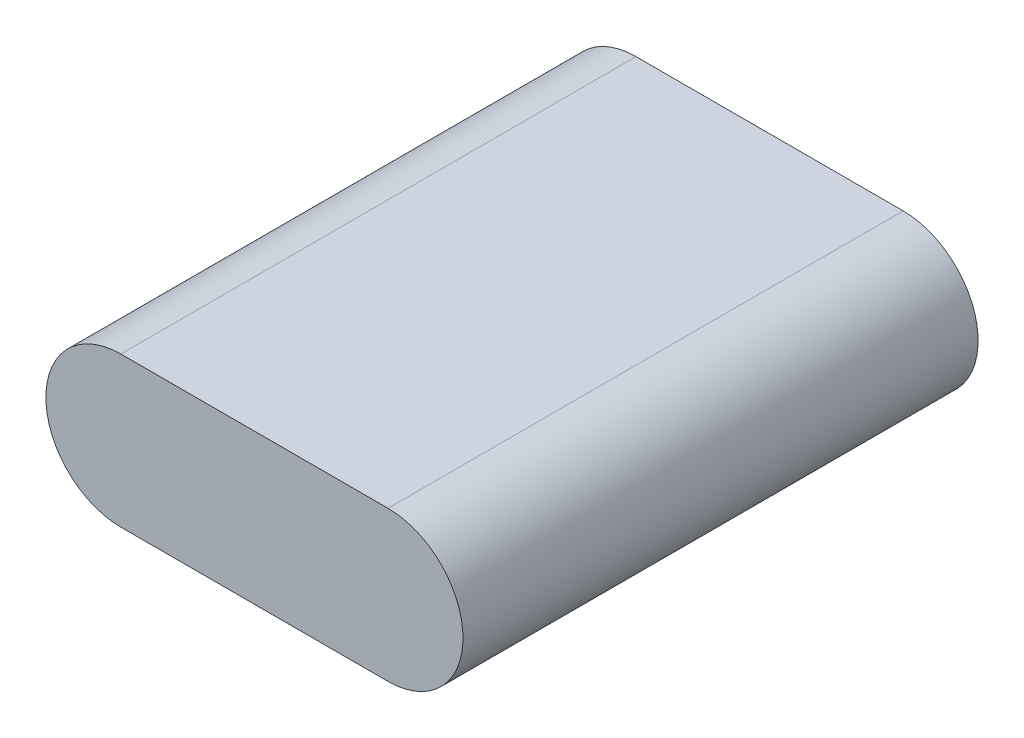
from build123d import *

# Parameters (mm, degrees)
BOSS_EXTRUDE1_DEPTH = 68.072


with BuildPart() as part:
    # Sketch3 → Boss-Extrude1 (new body)
    with BuildSketch(Plane.XY):
        with BuildLine():
            Line((-17.653, 9.906), (17.653, 9.906))
            ThreePointArc((17.653, 9.906), (27.559, 0), (17.653, -9.906))
            Line((17.653, -9.906), (-17.653, -9.906))
            ThreePointArc((-17.653, -9.906), (-27.559, 0), (-17.653, 9.906))
        make_face()
    extrude(amount=BOSS_EXTRUDE1_DEPTH)


solid = part.part
